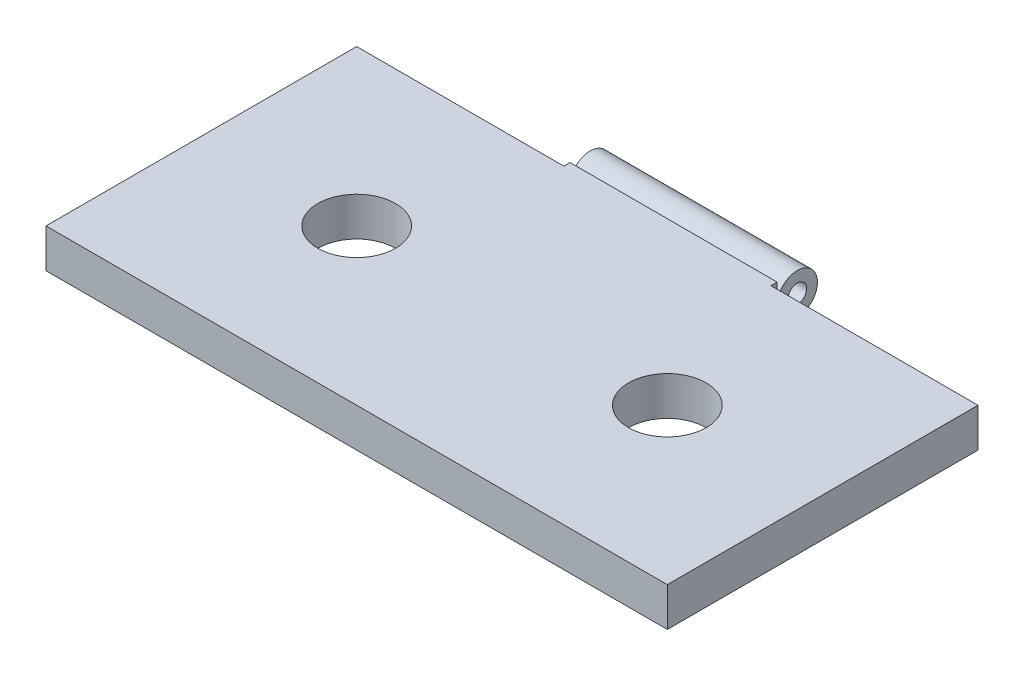
from build123d import *

# Parameters (mm, degrees)
CROQUIS3_W              = 50.8
CROQUIS3_H              = 25.4
CROQUIS3_R              = 3.175
SALIENTE_EXTRUIR1_DEPTH = 3.175
CROQUIS6_R              = 0.762
SALIENTE_EXTRUIR3_DEPTH = 8.466666667


with BuildPart() as part:
    # Croquis3 → Saliente-Extruir1 (new body)
    with BuildSketch(Plane(origin=(0, 0, 0), x_dir=(1, 0, 0), z_dir=(0, 1, 0))):
        Rectangle(CROQUIS3_W, CROQUIS3_H)
        with Locations((-12.7, 0)):
            Circle(CROQUIS3_R, mode=Mode.SUBTRACT)
        with Locations((12.7, 0)):
            Circle(CROQUIS3_R, mode=Mode.SUBTRACT)
    extrude(amount=SALIENTE_EXTRUIR1_DEPTH)

    # Croquis6 → Saliente-Extruir3 (add, symmetric)
    with BuildSketch(Plane.ZY):
        with BuildLine():
            Line((-12.7, 3.175), (-13.208, 3.175))
            Line((-13.208, 3.175), (-13.208, 2.437497499))
            ThreePointArc((-13.208, 2.437497499), (-13.301057822, 2.315117237), (-13.443857143, 2.372082497))
            ThreePointArc((-13.443857143, 2.372082497), (-16.51, 1.521687475), (-13.443857143, 0.671292453))
            ThreePointArc((-13.443857143, 0.671292453), (-13.301057822, 0.728257713), (-13.208, 0.605877451))
            Line((-13.208, 0.605877451), (-13.208, 0))
            Line((-13.208, 0), (-12.7, 0))
            Line((-12.7, 0), (-12.7, 3.175))
        make_face()
        with Locations((-14.859, 1.521687475)):
            Circle(CROQUIS6_R, mode=Mode.SUBTRACT)
    extrude(amount=SALIENTE_EXTRUIR3_DEPTH, both=True)


solid = part.part
